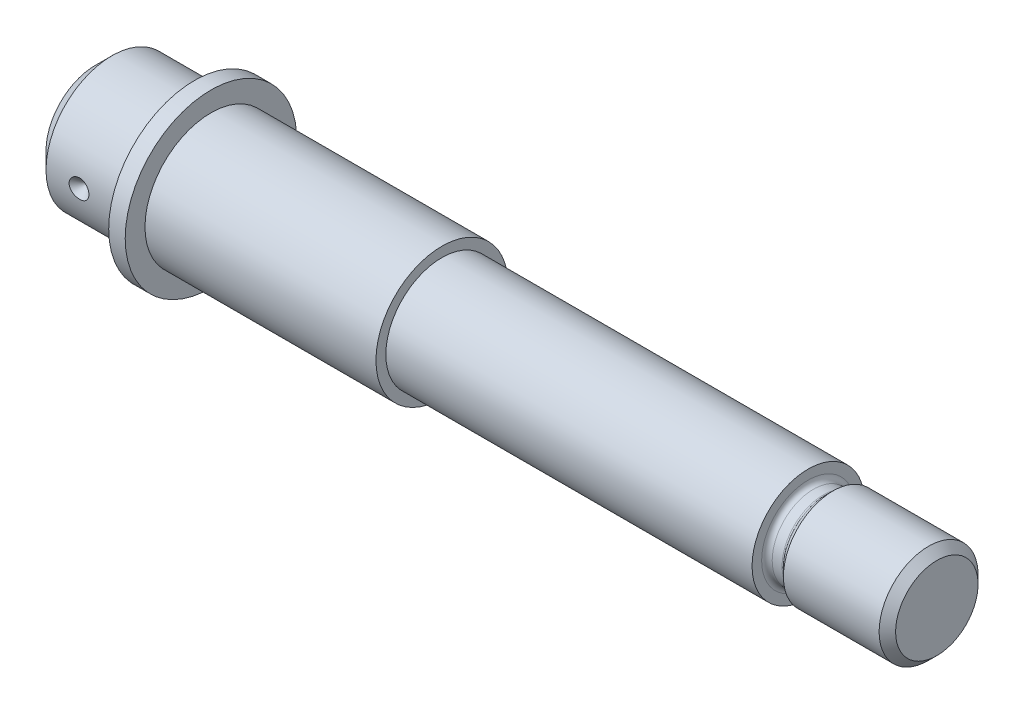
from build123d import *

# Parameters (mm, degrees)
CUT_EXTRUDE1_DEPTH = 4


with BuildPart() as part:
    # Sketch1 → Revolve1 (revolve)
    with BuildSketch(Plane(origin=(0, 0, 0), x_dir=(1, 0, 0), z_dir=(0, 1, 0))):
        with BuildLine():
            Line((0, 0), (0, -15))
            Line((0, -15), (5, -20))
            Line((5, -20), (30, -20))
            Line((30, -20), (30, -26))
            Line((30, -26), (35, -26))
            Line((35, -26), (35, -20))
            Line((35, -20), (105, -20))
            Line((105, -20), (105, -17))
            Line((105, -17), (216, -17))
            Line((216, -17), (216, -15))
            Line((216, -15), (216, -14.1))
            ThreePointArc((216, -14.1), (216.46862915, -12.96862915), (217.6, -12.5))
            Line((217.6, -12.5), (220.585786438, -12.5))
            ThreePointArc((220.585786438, -12.5), (220.96846987, -12.576120467), (221.292893219, -12.792893219))
            Line((221.292893219, -12.792893219), (223.5, -15))
            Line((223.5, -15), (252.5, -15))
            Line((252.5, -15), (255, -12.5))
            Line((255, -12.5), (255, 0))
            Line((255, 0), (0, 0))
        make_face()
    revolve(axis=Axis((-87.77690163, 0, 0), (1, 0, 0)))

    # Sketch5 → Cut-Revolve1 (revolve, cut)
    with BuildSketch(Plane.ZY.offset(-15)):
        Polygon((20, 0), (20, 3), (17, 0), align=None)
    revolve(axis=Axis((15, 0, 17), (0, 0, 1)), mode=Mode.SUBTRACT)

    # Sketch6 → Cut-Extrude1 (cut)
    with BuildSketch(Plane(origin=(0, 0, -20), x_dir=(-1, 0, 0), z_dir=(0, 0, -1))):
        with BuildLine():
            Line((-73, 6), (-53, 6))
            ThreePointArc((-53, 6), (-47, 0), (-53, -6))
            Line((-53, -6), (-73, -6))
            ThreePointArc((-73, -6), (-79, 0), (-73, 6))
        make_face()
    extrude(amount=-CUT_EXTRUDE1_DEPTH, mode=Mode.SUBTRACT)


solid = part.part
